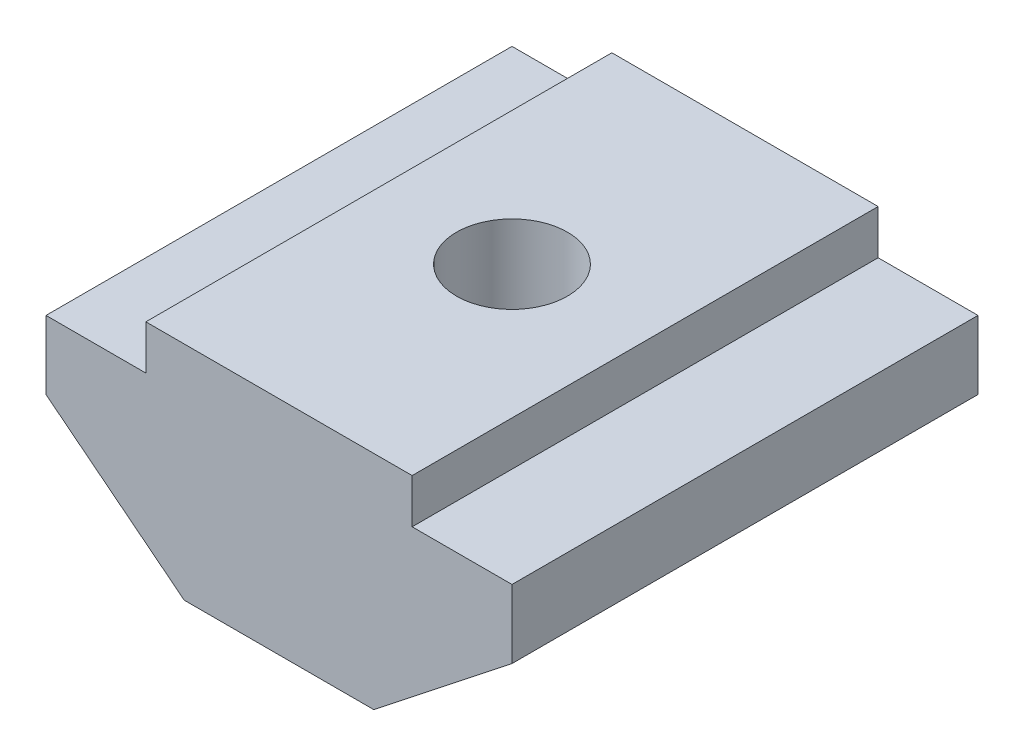
from build123d import *

# Parameters (mm, degrees)
BOSS_EXTRUDE1_DEPTH   = 10.5
M3X0_5_TAPPED_HOLE1_D = 2.5


with BuildPart() as part:
    # Sketch1 → Boss-Extrude1 (new body)
    with BuildSketch(Plane.XY):
        Polygon((-3, 5), (3, 5), (3, 4), (5.25, 4), (5.25, 2.455938691), (2.13559322, 0), (-2.13559322, 0), (-5.25, 2.455938691), (-5.25, 4), (-3, 4), align=None)
    extrude(amount=BOSS_EXTRUDE1_DEPTH)

    # M3x0.5 Tapped Hole1 (through all)
    with Locations(Plane(origin=(0, 5, 0), x_dir=(1, 0, 0), z_dir=(0, 1, 0))):
        with Locations((0, -5.25)):
            Hole(M3X0_5_TAPPED_HOLE1_D / 2)


solid = part.part
